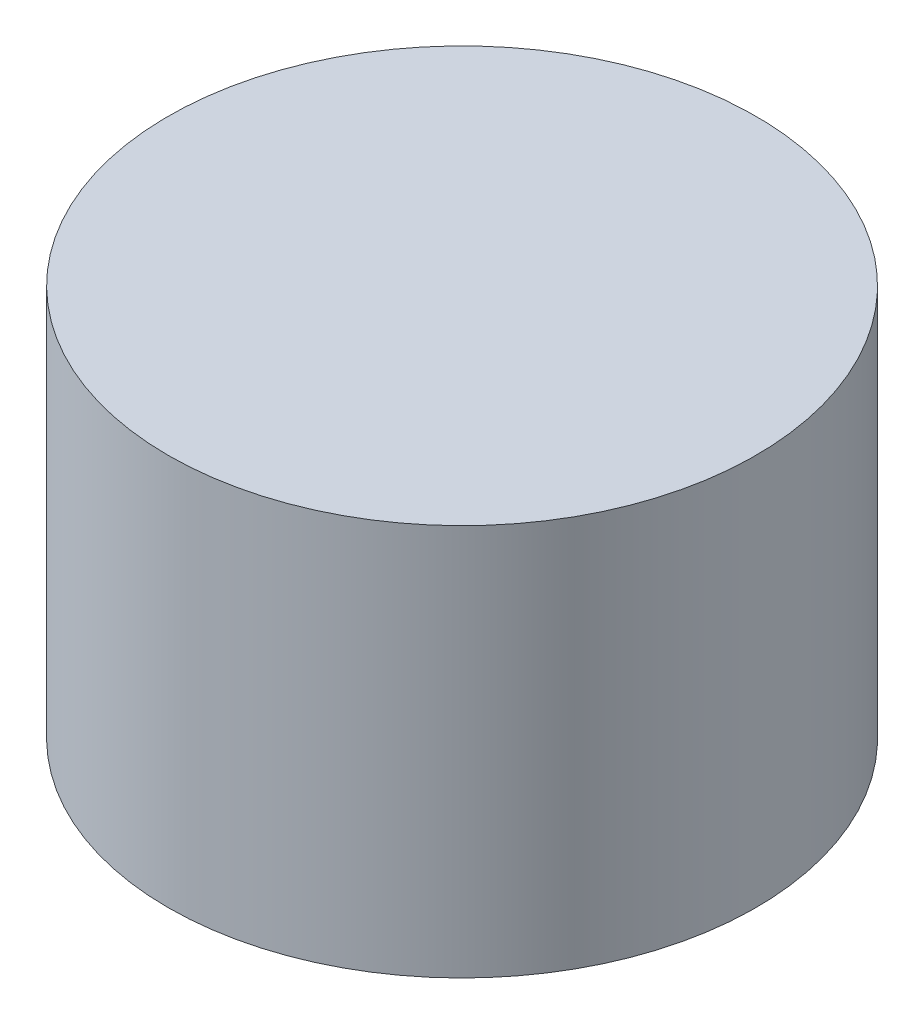
from build123d import *

# Parameters (mm, degrees)
SKETCH1_R           = 1.5
BOSS_EXTRUDE1_DEPTH = 2


with BuildPart() as part:
    # Sketch1 → Boss-Extrude1 (new body)
    with BuildSketch(Plane(origin=(0, 0, 0), x_dir=(1, 0, 0), z_dir=(0, 1, 0))):
        Circle(SKETCH1_R)
    extrude(amount=BOSS_EXTRUDE1_DEPTH)


solid = part.part
